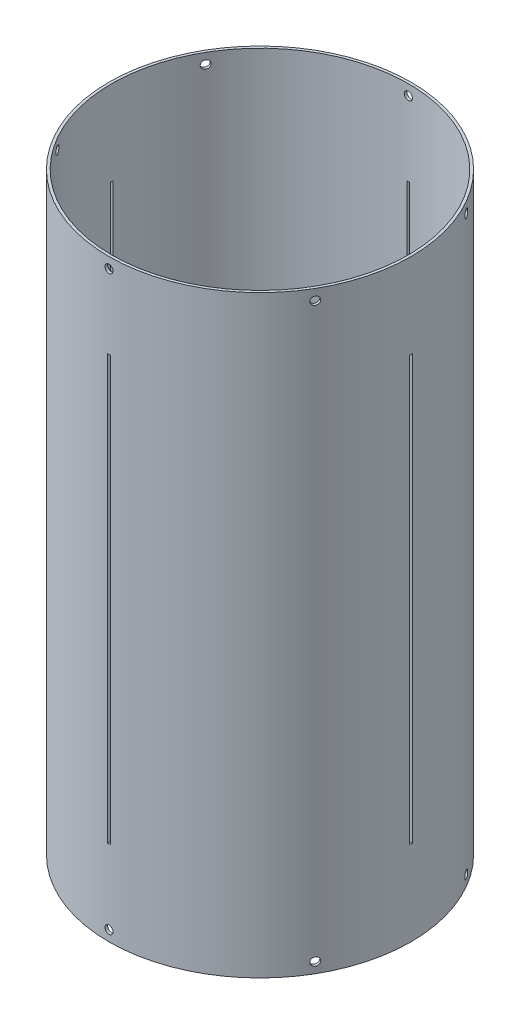
from build123d import *

# Parameters (mm, degrees)
SKETCH2_R           = 90.4875
SKETCH2_R_2         = 88.9
BOSS_EXTRUDE1_DEPTH = 355.6
SKETCH3_R           = 2.413
CUT_EXTRUDE1_DEPTH  = 91.4875
CIRPATTERN1_COUNT   = 6
SKETCH4_W           = 1.5875
SKETCH4_H           = 254
CUT_EXTRUDE2_DEPTH  = 2.54
CIRPATTERN2_COUNT   = 4


with BuildPart() as part:
    # Sketch2 → Boss-Extrude1 (new body)
    with BuildSketch(Plane(origin=(0, 0, 0), x_dir=(1, 0, 0), z_dir=(0, 1, 0))):
        Circle(SKETCH2_R)
        Circle(SKETCH2_R_2, mode=Mode.SUBTRACT)
    extrude(amount=BOSS_EXTRUDE1_DEPTH)

    # Sketch3 → Cut-Extrude1 (cut, symmetric)
    with BuildSketch(Plane.XY):
        with Locations((0, 349.25)):
            Circle(SKETCH3_R)
        with Locations((0, 6.35)):
            Circle(SKETCH3_R)
    cut_extrude1 = extrude(amount=CUT_EXTRUDE1_DEPTH, both=True, mode=Mode.SUBTRACT)

    # CirPattern1: Cut-Extrude1 ×6 about axis
    cirpattern1_axis = Axis((0, 355.6, 0), (0, 1, 0))
    for i in range(1, CIRPATTERN1_COUNT):
        add(cut_extrude1.rotate(cirpattern1_axis, i * 360 / CIRPATTERN1_COUNT), mode=Mode.SUBTRACT)

    # Sketch4 → Cut-Extrude2 (cut)
    with BuildSketch(Plane.ZY.offset(90.4875)):
        with Locations((0, 177.8)):
            Rectangle(SKETCH4_W, SKETCH4_H)
    cut_extrude2 = extrude(amount=-CUT_EXTRUDE2_DEPTH, mode=Mode.SUBTRACT)

    # CirPattern2: Cut-Extrude2 ×4 about axis
    cirpattern2_axis = Axis((0, 0, 0), (0, 1, 0))
    for i in range(1, CIRPATTERN2_COUNT):
        add(cut_extrude2.rotate(cirpattern2_axis, i * 360 / CIRPATTERN2_COUNT), mode=Mode.SUBTRACT)


solid = part.part
